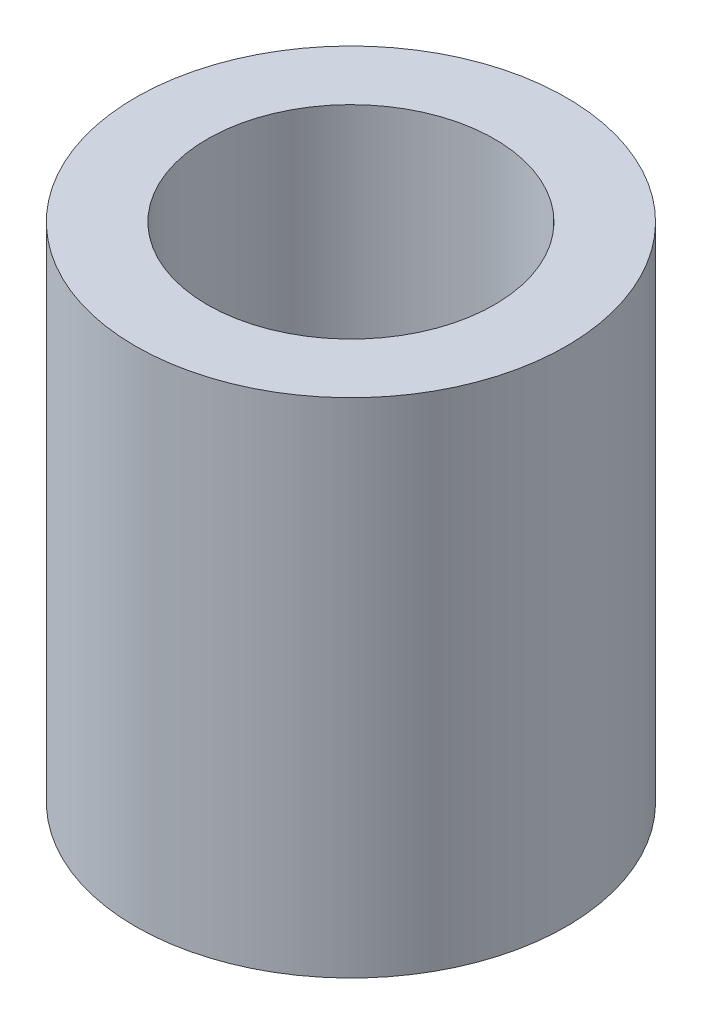
from build123d import *

# Parameters (mm, degrees)
SKETCH_1_R      = 3
SKETCH_1_R_2    = 2
EXTRUDE_1_DEPTH = 7


with BuildPart() as part:
    # Эскиз1 → Бобышка-Вытянуть1 (new body)
    with BuildSketch(Plane(origin=(0, 0, 0), x_dir=(1, 0, 0), z_dir=(0, 1, 0))):
        Circle(SKETCH_1_R)
        Circle(SKETCH_1_R_2, mode=Mode.SUBTRACT)
    extrude(amount=EXTRUDE_1_DEPTH)


solid = part.part
